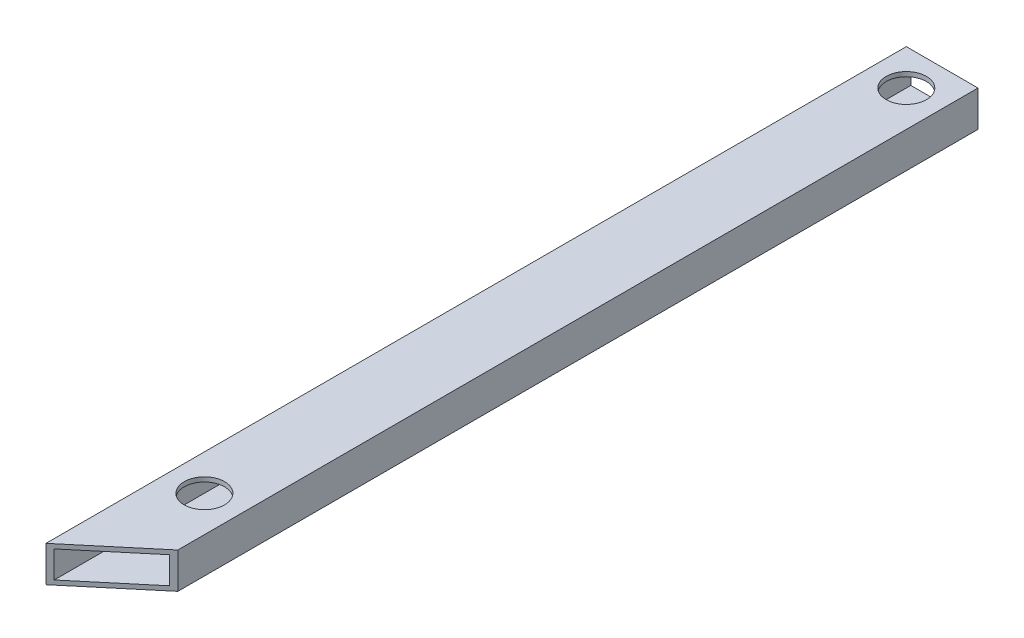
from build123d import *

# Parameters (mm, degrees)
SKETCH1_W           = 50.8
SKETCH1_H           = 25.4
BOSS_EXTRUDE1_DEPTH = 609.6
SKETCH2_W           = 44.45
SKETCH2_H           = 19.05
CUT_EXTRUDE1_DEPTH  = 609.6
CUT_EXTRUDE3_DEPTH  = 25.4
SKETCH6_R           = 14.2875
CUT_EXTRUDE5_DEPTH  = 3.175
SKETCH8_R           = 14.2875
CUT_EXTRUDE7_DEPTH  = 3.175


with BuildPart() as part:
    # Sketch1 → Boss-Extrude1 (new body)
    with BuildSketch(Plane.XY):
        with Locations((25.4, 12.7)):
            Rectangle(SKETCH1_W, SKETCH1_H)
    extrude(amount=BOSS_EXTRUDE1_DEPTH)

    # Sketch2 → Cut-Extrude1 (cut)
    with BuildSketch(Plane(origin=(0, 0, 0), x_dir=(-1, 0, 0), z_dir=(0, 0, -1))):
        with Locations((-25.4, 12.7)):
            Rectangle(SKETCH2_W, SKETCH2_H)
    extrude(amount=-CUT_EXTRUDE1_DEPTH, mode=Mode.SUBTRACT)

    # Sketch4 → Cut-Extrude3 (cut)
    with BuildSketch(Plane.XZ):
        Polygon((0, 609.6), (50.8, 566.973738736), (50.8, 609.6), align=None)
    extrude(amount=-CUT_EXTRUDE3_DEPTH, mode=Mode.SUBTRACT)

    # Sketch6 → Cut-Extrude5 (cut)
    with BuildSketch(Plane(origin=(0, 25.4, 0), x_dir=(1, 0, 0), z_dir=(0, 1, 0))):
        with Locations((25.4, -25.4)):
            Circle(SKETCH6_R)
    extrude(amount=-CUT_EXTRUDE5_DEPTH, mode=Mode.SUBTRACT)

    # Sketch8 → Cut-Extrude7 (cut)
    with BuildSketch(Plane(origin=(0, 25.4, 0), x_dir=(1, 0, 0), z_dir=(0, 1, 0))):
        with Locations((25.4, -522.762581257)):
            Circle(SKETCH8_R)
    extrude(amount=-CUT_EXTRUDE7_DEPTH, mode=Mode.SUBTRACT)


solid = part.part
